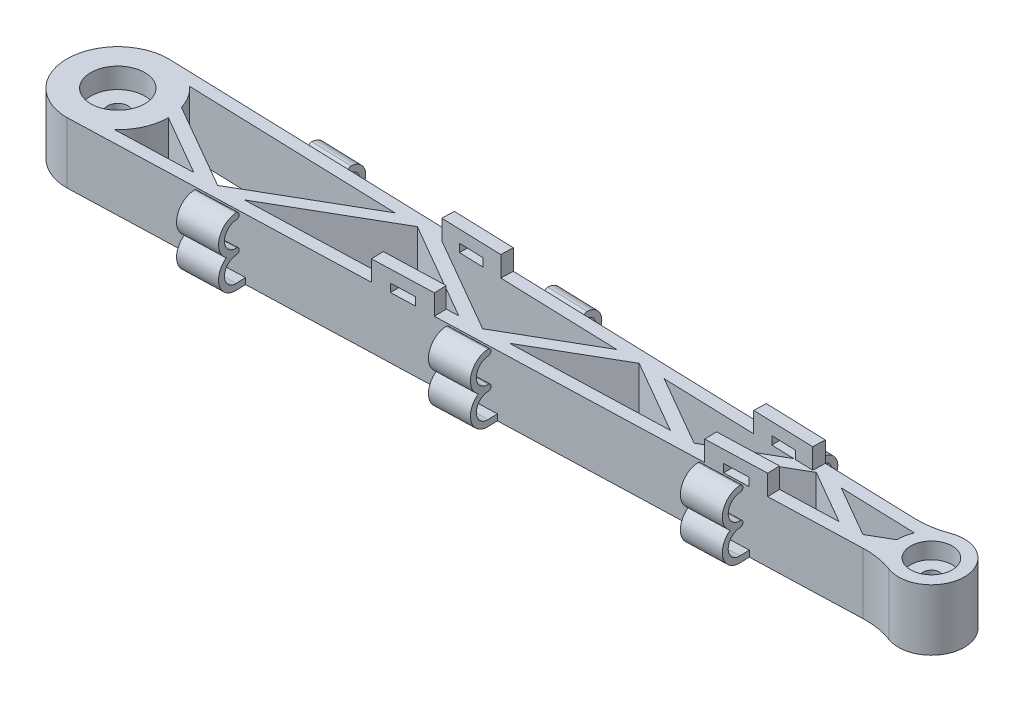
from build123d import *

# Parameters (mm, degrees)
SKETCH1_R                = 6.65
BOSS_EXTRUDE1_DEPTH      = 15
SKETCH2_R                = 6.65
SKETCH2_R_2              = 2.5
BOSS_EXTRUDE2_DEPTH      = 5
SKETCH3_R                = 8.1
SKETCH3_R_2              = 5.1
BOSS_EXTRUDE3_DEPTH      = 15
SKETCH4_R                = 5.1
CUT_EXTRUDE1_DEPTH       = 16
FILLET1_R                = 20
SKETCH5_R                = 5.1
SKETCH5_R_2              = 2
BOSS_EXTRUDE4_DEPTH      = 1
BOSS_EXTRUDE4_DEPTH_BACK = 6
BOSS_EXTRUDE5_DEPTH      = 5
SKETCH8_W                = 6
SKETCH8_H                = 2
CUT_EXTRUDE3_DEPTH       = 12
CUT_EXTRUDE3_DEPTH_BACK  = 12
BOSS_EXTRUDE6_DEPTH      = 10
BOSS_EXTRUDE7_DEPTH      = 10
BOSS_EXTRUDE8_DEPTH      = 10
BOSS_EXTRUDE9_DEPTH      = 10
BOSS_EXTRUDE10_DEPTH     = 10
BOSS_EXTRUDE11_DEPTH     = 10


with BuildPart() as part:
    # Sketch1 → Boss-Extrude1 (new body)
    with BuildSketch(Plane(origin=(0, 0, 0), x_dir=(1, 0, 0), z_dir=(0, 1, 0))):
        with BuildLine():
            Line((0, -12.5), (200, -6))
            Line((200, -6), (200, 6))
            Line((200, 6), (0, 12.5))
            ThreePointArc((0, 12.5), (-12.5, 0), (0, -12.5))
        make_face()
        with BuildLine():
            Line((27.305741081, -8.610979458), (8.435827248, -9.224251658))
            ThreePointArc((8.435827248, -9.224251658), (11.426226876, -5.068662485), (12.499842297, -0.06278981))
            Line((12.499842297, -0.06278981), (27.305741081, -8.610979458))
        make_face(mode=Mode.SUBTRACT)
        Polygon((90.383925047, -6.560938479), (39.343886955, -8.219739717), (66.300470013, 7.343650768), align=None, mode=Mode.SUBTRACT)
        Polygon((140.732488216, -4.924610176), (102.422070922, -6.169698738), (122.655557893, 5.512110412), align=None, mode=Mode.SUBTRACT)
        Polygon((180.92035752, -3.618504424), (152.770634091, -4.533370435), (167.637793012, 4.05018777), align=None, mode=Mode.SUBTRACT)
        Polygon((197, -3.095916043), (192.958503395, -3.227264683), (197, -0.89390553), align=None, mode=Mode.SUBTRACT)
        Circle(SKETCH1_R, mode=Mode.SUBTRACT)
        with BuildLine():
            ThreePointArc((11.930505504, 3.730018556), (10.54720469, 6.708686401), (8.435827248, 9.224251658))
            Line((8.435827248, 9.224251658), (60.62022063, 7.528258873))
            Line((60.62022063, 7.528258873), (32.985990463, -8.426371353))
            Line((32.985990463, -8.426371353), (11.930505504, 3.730018556))
        make_face(mode=Mode.SUBTRACT)
        Polygon((96.06417443, -6.376330374), (72.658366505, 7.137019132), (116.975308511, 5.696718517), align=None, mode=Mode.SUBTRACT)
        Polygon((146.412737599, -4.740002071), (129.013454385, 5.305478776), (161.957543629, 4.234795875), align=None, mode=Mode.SUBTRACT)
        Polygon((173.995689504, 3.843556134), (197, 3.095916043), (197, 2.570196085), (186.600606903, -3.433896319), align=None, mode=Mode.SUBTRACT)
    extrude(amount=BOSS_EXTRUDE1_DEPTH)

    # Sketch2 → Boss-Extrude2 (add)
    with BuildSketch(Plane(origin=(0, 10, 0), x_dir=(1, 0, 0), z_dir=(0, 1, 0))):
        Circle(SKETCH2_R)
        Circle(SKETCH2_R_2, mode=Mode.SUBTRACT)
    extrude(amount=-BOSS_EXTRUDE2_DEPTH)

    # Sketch3 → Boss-Extrude3 (add, through all)
    with BuildSketch(Plane(origin=(0, 15, 0), x_dir=(1, 0, 0), z_dir=(0, 1, 0))):
        with Locations((200, 0)):
            Circle(SKETCH3_R)
        with Locations((200, 0)):
            Circle(SKETCH3_R_2, mode=Mode.SUBTRACT)
    extrude(amount=-BOSS_EXTRUDE3_DEPTH)

    # Sketch4 → Cut-Extrude1 (cut, through all)
    with BuildSketch(Plane(origin=(0, 15, 0), x_dir=(1, 0, 0), z_dir=(0, 1, 0))):
        with Locations((200, 0)):
            Circle(SKETCH4_R)
    extrude(amount=-CUT_EXTRUDE1_DEPTH, mode=Mode.SUBTRACT)

    # Fillet1
    fillet1_edges = [part.edges().sort_by_distance(p)[0] for p in [
        (194.752671295, 7.5, 6.170538183),
        (194.752671295, 7.5, -6.170538183),
    ]]
    fillet(fillet1_edges, radius=FILLET1_R)

    # Sketch5 → Boss-Extrude4 (add, two sides)
    with BuildSketch(Plane(origin=(0, 10, 0), x_dir=(1, 0, 0), z_dir=(0, 1, 0))) as boss_extrude4_sk:
        with Locations((200, 0)):
            Circle(SKETCH5_R)
        with Locations((200, 0)):
            Circle(SKETCH5_R_2, mode=Mode.SUBTRACT)
    extrude(amount=BOSS_EXTRUDE4_DEPTH)
    extrude(boss_extrude4_sk.sketch, amount=-BOSS_EXTRUDE4_DEPTH_BACK)

    # Sketch6 → Boss-Extrude5 (add)
    with BuildSketch(Plane(origin=(0, 15, 0), x_dir=(1, 0, 0), z_dir=(0, 1, 0))):
        Polygon((151.846343716, 7.564993829), (166.838428111, 7.077751086), (166.740979562, 4.079334207), (151.748895167, 4.56657695), align=None)
        Polygon((72.598030251, 10.140564017), (87.590114646, 9.653321274), (87.492666097, 6.654904395), (72.500581702, 7.142147138), align=None)
        Polygon((166.838428111, -7.077751086), (151.846343716, -7.564993829), (151.748895167, -4.56657695), (166.740979562, -4.079334207), align=None)
        Polygon((87.492666097, -9.656488352), (72.500581702, -10.143731095), (72.403133154, -7.145314216), (87.395217549, -6.658071473), align=None)
    extrude(amount=BOSS_EXTRUDE5_DEPTH)

    # Sketch8 → Cut-Extrude3 (cut, two sides)
    with BuildSketch(Plane.XY) as cut_extrude3_sk:
        with Locations((80.000581702, 16)):
            Rectangle(SKETCH8_W, SKETCH8_H)
        with Locations((159.346343716, 16)):
            Rectangle(SKETCH8_W, SKETCH8_H)
    extrude(amount=CUT_EXTRUDE3_DEPTH, mode=Mode.SUBTRACT)
    extrude(cut_extrude3_sk.sketch, amount=-CUT_EXTRUDE3_DEPTH_BACK, mode=Mode.SUBTRACT)

    # Sketch9 → Boss-Extrude6 (add)
    with BuildSketch(Plane(origin=(32.213317179, 0, 1.046932808), x_dir=(-0.03248285, 0, 0.999472293), z_dir=(-0.999472293, 0, -0.03248285))):
        with BuildLine():
            ThreePointArc((-15.993403663, 5.5), (-17.993403663, 3.5), (-15.993403663, 1.5))
            Line((-15.993403663, 1.5), (-12.493403663, 1.5))
            Line((-12.493403663, 1.5), (-12.493403663, 0))
            Line((-12.493403663, 0), (-15.993403663, 0))
            ThreePointArc((-15.993403663, 0), (-19.300592801, 2.354356076), (-18.158467172, 6.25))
            ThreePointArc((-18.158467172, 6.25), (-19.300592801, 10.145643924), (-15.993403663, 12.5))
            ThreePointArc((-15.993403663, 12.5), (-15.243403663, 11.75), (-15.993403663, 11))
            ThreePointArc((-15.993403663, 11), (-17.993403663, 9), (-15.993403663, 7))
            ThreePointArc((-15.993403663, 7), (-15.243403663, 6.25), (-15.993403663, 5.5))
        make_face()
    extrude(amount=-BOSS_EXTRUDE6_DEPTH)

    # Sketch10 → Boss-Extrude7 (add)
    with BuildSketch(Plane(origin=(92.18165476, 0, 2.99590378), x_dir=(0.03248285, 0, -0.999472293), z_dir=(0.999472293, 0, 0.03248285))):
        with BuildLine():
            Line((15.993403663, 1.5), (12.493403663, 1.5))
            Line((12.493403663, 1.5), (12.493403663, 0))
            Line((12.493403663, 0), (15.993403663, 0))
            ThreePointArc((15.993403663, 0), (19.300592801, 2.354356076), (18.158467172, 6.25))
            ThreePointArc((18.158467172, 6.25), (19.300592801, 10.145643924), (15.993403663, 12.5))
            ThreePointArc((15.993403663, 12.5), (15.243403663, 11.75), (15.993403663, 11))
            ThreePointArc((15.993403663, 11), (17.993403663, 9), (15.993403663, 7))
            ThreePointArc((15.993403663, 7), (15.243403663, 6.25), (15.993403663, 5.5))
            ThreePointArc((15.993403663, 5.5), (17.993403663, 3.5), (15.993403663, 1.5))
        make_face()
    extrude(amount=BOSS_EXTRUDE7_DEPTH)

    # Sketch11 → Boss-Extrude8 (add)
    with BuildSketch(Plane(origin=(152.14999234, 0, 4.944874751), x_dir=(0.03248285, 0, -0.999472293), z_dir=(0.999472293, 0, 0.03248285))):
        with BuildLine():
            Line((15.993403663, 1.5), (12.493403663, 1.5))
            Line((12.493403663, 1.5), (12.493403663, 0))
            Line((12.493403663, 0), (15.993403663, 0))
            ThreePointArc((15.993403663, 0), (19.300592801, 2.354356076), (18.158467172, 6.25))
            ThreePointArc((18.158467172, 6.25), (19.300592801, 10.145643924), (15.993403663, 12.5))
            ThreePointArc((15.993403663, 12.5), (15.243403663, 11.75), (15.993403663, 11))
            ThreePointArc((15.993403663, 11), (17.993403663, 9), (15.993403663, 7))
            ThreePointArc((15.993403663, 7), (15.243403663, 6.25), (15.993403663, 5.5))
            ThreePointArc((15.993403663, 5.5), (17.993403663, 3.5), (15.993403663, 1.5))
        make_face()
    extrude(amount=BOSS_EXTRUDE8_DEPTH)

    # Sketch12 → Boss-Extrude9 (add)
    with BuildSketch(Plane(origin=(32.115868631, 0, -1.043765731), x_dir=(0.03248285, 0, 0.999472293), z_dir=(-0.999472293, 0, 0.03248285))):
        with BuildLine():
            Line((14.858185969, 0), (10.367682188, 0))
            Line((10.367682188, 0), (10.367682188, 1.5))
            Line((10.367682188, 1.5), (14.858185969, 1.5))
            add(Edge.make_bspline(
                [(14.858185969, 1.5), (17.851855156, 1.5), (17.851855156, 4.5), (17.851855156, 7.5), (14.858185969, 7.5)],
                knots=[3.141592654, 3.141592654, 3.141592654, 4.71238898, 4.71238898, 6.283185307, 6.283185307, 6.283185307], degree=2, weights=[1, 0.707106781, 1, 0.707106781, 1]))
            add(Edge.make_bspline(
                [(14.858185969, 9), (14.109768672, 9), (14.109768672, 8.25), (14.109768672, 7.5), (14.858185969, 7.5)],
                knots=[0, 0, 0, 1.570796327, 1.570796327, 3.141592654, 3.141592654, 3.141592654], degree=2, weights=[1, 0.707106781, 1, 0.707106781, 1]))
            add(Edge.make_bspline(
                [(14.858185969, 9), (17.851855156, 9), (17.851855156, 12), (17.851855156, 15), (14.858185969, 15)],
                knots=[3.141592654, 3.141592654, 3.141592654, 4.71238898, 4.71238898, 6.283185307, 6.283185307, 6.283185307], degree=2, weights=[1, 0.707106781, 1, 0.707106781, 1]))
            add(Edge.make_bspline(
                [(14.858185969, 16.5), (14.109768672, 16.5), (14.109768672, 15.75), (14.109768672, 15), (14.858185969, 15)],
                knots=[0, 0, 0, 1.570796327, 1.570796327, 3.141592654, 3.141592654, 3.141592654], degree=2, weights=[1, 0.707106781, 1, 0.707106781, 1]))
            add(Edge.make_bspline(
                [(17.340405329, 8.25), (29.751502128, 16.5), (14.858185969, 16.5)],
                knots=[3.727278197, 3.727278197, 3.727278197, 6.283185307, 6.283185307, 6.283185307], degree=2, weights=[1, 0.288675135, 1]))
            add(Edge.make_bspline(
                [(14.858185969, 0), (29.751502128, 0), (17.340405329, 8.25)],
                knots=[3.141592654, 3.141592654, 3.141592654, 5.697499764, 5.697499764, 5.697499764], degree=2, weights=[1, 0.288675135, 1]))
        make_face()
    extrude(amount=-BOSS_EXTRUDE9_DEPTH)

    # Sketch13 → Boss-Extrude10 (add)
    with BuildSketch(Plane(origin=(92.084206211, 0, -2.992736702), x_dir=(-0.03248285, 0, -0.999472293), z_dir=(0.999472293, 0, -0.03248285))):
        with BuildLine():
            Line((-14.858185969, 0), (-12.493403663, 0))
            Line((-12.493403663, 0), (-12.493403663, 1.5))
            Line((-12.493403663, 1.5), (-14.858185969, 1.5))
            add(Edge.make_bspline(
                [(-14.858185969, 7.5), (-17.851855156, 7.5), (-17.851855156, 4.5), (-17.851855156, 1.5), (-14.858185969, 1.5)],
                knots=[0, 0, 0, 1.570796327, 1.570796327, 3.141592654, 3.141592654, 3.141592654], degree=2, weights=[1, 0.707106781, 1, 0.707106781, 1]))
            add(Edge.make_bspline(
                [(-14.858185969, 7.5), (-14.109768672, 7.5), (-14.109768672, 8.25), (-14.109768672, 9), (-14.858185969, 9)],
                knots=[3.141592654, 3.141592654, 3.141592654, 4.71238898, 4.71238898, 6.283185307, 6.283185307, 6.283185307], degree=2, weights=[1, 0.707106781, 1, 0.707106781, 1]))
            add(Edge.make_bspline(
                [(-14.858185969, 15), (-17.851855156, 15), (-17.851855156, 12), (-17.851855156, 9), (-14.858185969, 9)],
                knots=[0, 0, 0, 1.570796327, 1.570796327, 3.141592654, 3.141592654, 3.141592654], degree=2, weights=[1, 0.707106781, 1, 0.707106781, 1]))
            add(Edge.make_bspline(
                [(-14.858185969, 15), (-14.109768672, 15), (-14.109768672, 15.75), (-14.109768672, 16.5), (-14.858185969, 16.5)],
                knots=[3.141592654, 3.141592654, 3.141592654, 4.71238898, 4.71238898, 6.283185307, 6.283185307, 6.283185307], degree=2, weights=[1, 0.707106781, 1, 0.707106781, 1]))
            add(Edge.make_bspline(
                [(-14.858185969, 16.5), (-29.751502128, 16.5), (-17.340405329, 8.25)],
                knots=[0, 0, 0, 2.55590711, 2.55590711, 2.55590711], degree=2, weights=[1, 0.288675135, 1]))
            add(Edge.make_bspline(
                [(-17.340405329, 8.25), (-29.751502128, 0), (-14.858185969, 0)],
                knots=[0.585685543, 0.585685543, 0.585685543, 3.141592654, 3.141592654, 3.141592654], degree=2, weights=[1, 0.288675135, 1]))
        make_face()
    extrude(amount=BOSS_EXTRUDE10_DEPTH)

    # Sketch14 → Boss-Extrude11 (add)
    with BuildSketch(Plane(origin=(152.052543792, 0, -4.941707673), x_dir=(-0.03248285, 0, -0.999472293), z_dir=(0.999472293, 0, -0.03248285))):
        with BuildLine():
            Line((-14.858185969, 0), (-12.493403663, 0))
            Line((-12.493403663, 0), (-12.493403663, 1.5))
            Line((-12.493403663, 1.5), (-14.858185969, 1.5))
            add(Edge.make_bspline(
                [(-14.858185969, 7.5), (-17.851855156, 7.5), (-17.851855156, 4.5), (-17.851855156, 1.5), (-14.858185969, 1.5)],
                knots=[0, 0, 0, 1.570796327, 1.570796327, 3.141592654, 3.141592654, 3.141592654], degree=2, weights=[1, 0.707106781, 1, 0.707106781, 1]))
            add(Edge.make_bspline(
                [(-14.858185969, 7.5), (-14.109768672, 7.5), (-14.109768672, 8.25), (-14.109768672, 9), (-14.858185969, 9)],
                knots=[3.141592654, 3.141592654, 3.141592654, 4.71238898, 4.71238898, 6.283185307, 6.283185307, 6.283185307], degree=2, weights=[1, 0.707106781, 1, 0.707106781, 1]))
            add(Edge.make_bspline(
                [(-14.858185969, 15), (-17.851855156, 15), (-17.851855156, 12), (-17.851855156, 9), (-14.858185969, 9)],
                knots=[0, 0, 0, 1.570796327, 1.570796327, 3.141592654, 3.141592654, 3.141592654], degree=2, weights=[1, 0.707106781, 1, 0.707106781, 1]))
            add(Edge.make_bspline(
                [(-14.858185969, 15), (-14.109768672, 15), (-14.109768672, 15.75), (-14.109768672, 16.5), (-14.858185969, 16.5)],
                knots=[3.141592654, 3.141592654, 3.141592654, 4.71238898, 4.71238898, 6.283185307, 6.283185307, 6.283185307], degree=2, weights=[1, 0.707106781, 1, 0.707106781, 1]))
            add(Edge.make_bspline(
                [(-14.858185969, 16.5), (-29.751502128, 16.5), (-17.340405329, 8.25)],
                knots=[0, 0, 0, 2.55590711, 2.55590711, 2.55590711], degree=2, weights=[1, 0.288675135, 1]))
            add(Edge.make_bspline(
                [(-17.340405329, 8.25), (-29.751502128, 0), (-14.858185969, 0)],
                knots=[0.585685543, 0.585685543, 0.585685543, 3.141592654, 3.141592654, 3.141592654], degree=2, weights=[1, 0.288675135, 1]))
        make_face()
    extrude(amount=BOSS_EXTRUDE11_DEPTH)


solid = part.part
